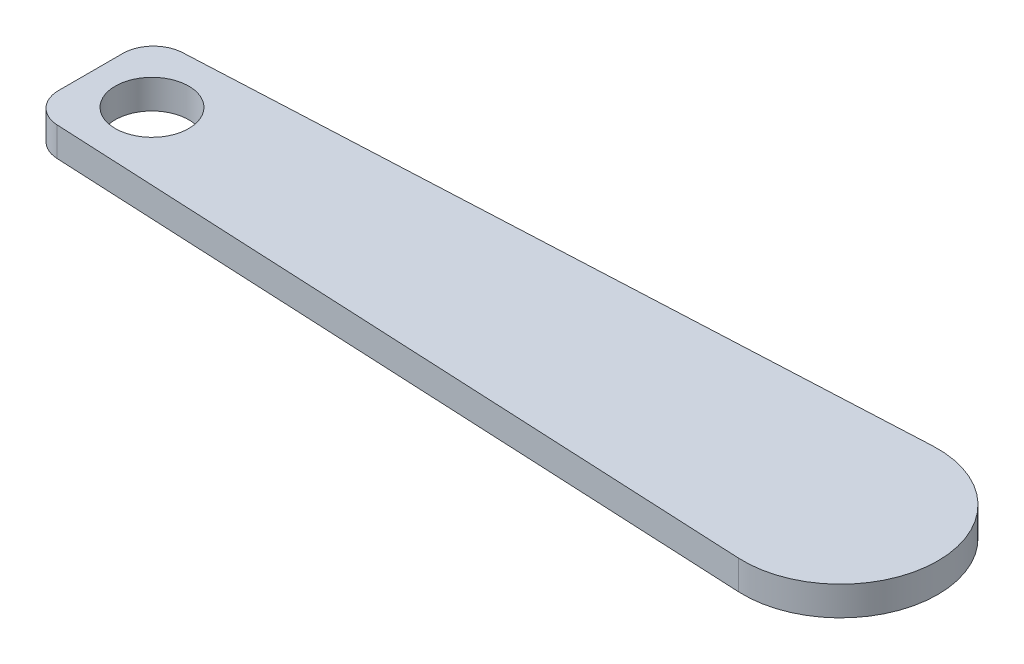
from build123d import *

# Parameters (mm, degrees)
SKETCH2_R           = 6
BOSS_EXTRUDE1_DEPTH = 4.7625
FILLET1_R           = 5


with BuildPart() as part:
    # Sketch2 → Boss-Extrude1 (new body)
    with BuildSketch(Plane(origin=(0, 0, 0), x_dir=(1, 0, 0), z_dir=(0, 1, 0))):
        with BuildLine():
            Line((-122.387926706, -10), (-0.763550737, -15.856626857))
            ThreePointArc((-0.763550737, -15.856626857), (15.875, -1.57e-07), (-0.763550423, 15.856626872))
            Line((-0.763550423, 15.856626872), (-122.387926706, 10))
            Line((-122.387926706, 10), (-122.387926706, -10))
        make_face()
        with Locations((-112.387926706, 0)):
            Circle(SKETCH2_R, mode=Mode.SUBTRACT)
    extrude(amount=BOSS_EXTRUDE1_DEPTH)

    # Fillet1
    fillet1_edges = [part.edges().sort_by_distance(p)[0] for p in [
        (-122.387926706, 2.38125, 10),
        (-122.387926706, 2.38125, -10),
    ]]
    fillet(fillet1_edges, radius=FILLET1_R)


solid = part.part
